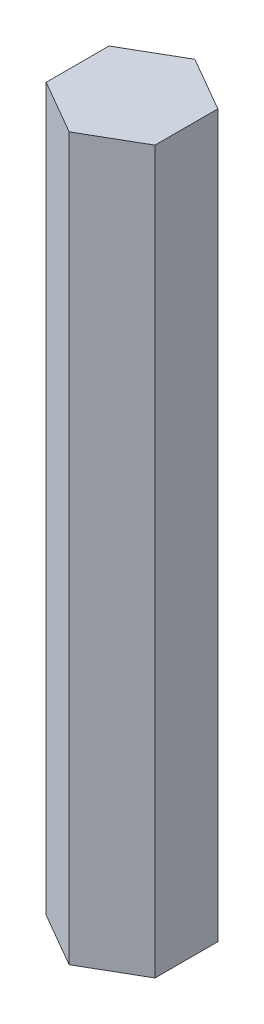
from build123d import *

# Parameters (mm, degrees)
BOSS_EXTRUDE1_DEPTH = 33.528


with BuildPart() as part:
    # Sketch1 → Boss-Extrude1 (new body)
    with BuildSketch(Plane(origin=(0, 0, 0), x_dir=(1, 0, 0), z_dir=(0, 1, 0))):
        Polygon((1.264830102, 5.11175), (-1.264830102, 3.65125), (-1.264830102, 0.73025), (1.264830102, -0.73025), (3.794490307, 0.73025), (3.794490307, 3.65125), align=None)
    extrude(amount=BOSS_EXTRUDE1_DEPTH)


solid = part.part
